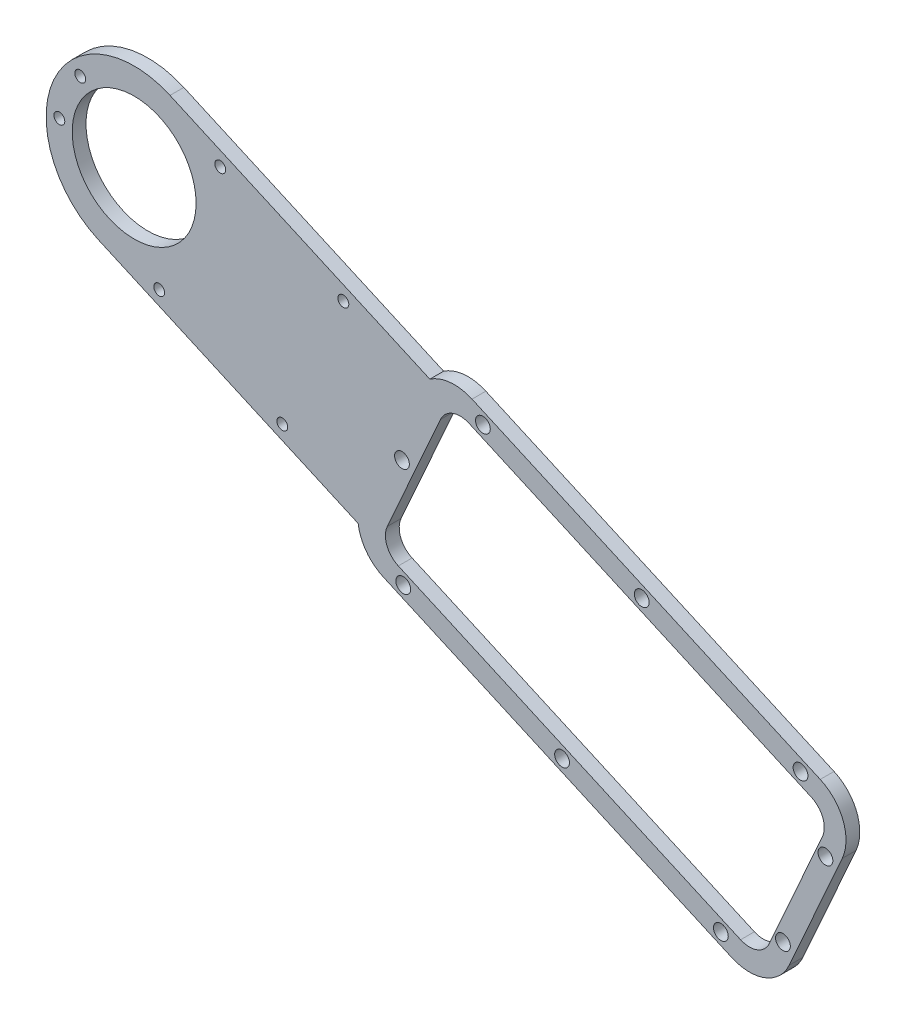
from build123d import *

# Parameters (mm, degrees)
SKETCH1_R           = 1.7
SKETCH1_R_2         = 14.25
SKETCH1_R_3         = 1.25
BOSS_EXTRUDE1_DEPTH = 3.175


with BuildPart() as part:
    # Sketch1 → Boss-Extrude1 (new body)
    with BuildSketch(Plane(origin=(0, 0, 0), x_dir=(-1, 0, 0), z_dir=(0, 0, -1))):
        with BuildLine():
            Line((67.653220557, 77.632201435), (79.867786674, 50.231391692))
            ThreePointArc((79.867786674, 50.231391692), (85.421957972, 44.965480094), (93.072911961, 45.169310483))
            Line((93.072911961, 45.169310483), (173.174612442, 80.876558766))
            ThreePointArc((173.174612442, 80.876558766), (177.109561802, 84.018800254), (179.014269534, 88.680301782))
            Line((179.014269534, 88.680301782), (238.78902448, 115.326328059))
            ThreePointArc((238.78902448, 115.326328059), (249.039738928, 142.066706765), (222.299360222, 152.317421212))
            Line((222.299360222, 152.317421212), (162.524605276, 125.671394934))
            ThreePointArc((162.524605276, 125.671394934), (157.784388135, 127.370762315), (152.817002247, 126.544575004))
            Line((152.817002247, 126.544575004), (72.715301765, 90.837326721))
            ThreePointArc((72.715301765, 90.837326721), (67.449390168, 85.283155423), (67.653220557, 77.632201435))
        make_face()
        with Locations((168.932649456, 106.357056211)):
            Circle(SKETCH1_R, mode=Mode.SUBTRACT)
        with Locations((71.52342211, 76.072861852)):
            Circle(SKETCH1_R, mode=Mode.SUBTRACT)
        with Locations((81.295075004, 54.152214057)):
            Circle(SKETCH1_R, mode=Mode.SUBTRACT)
        with Locations((77.249619525, 90.121461895)):
            Circle(SKETCH1_R, mode=Mode.SUBTRACT)
        with Locations((113.784032516, 106.407550051)):
            Circle(SKETCH1_R, mode=Mode.SUBTRACT)
        with Locations((150.318445506, 122.693638207)):
            Circle(SKETCH1_R, mode=Mode.SUBTRACT)
        with Locations((168.640294682, 81.592423593)):
            Circle(SKETCH1_R, mode=Mode.SUBTRACT)
        with Locations((132.105881692, 65.306335437)):
            Circle(SKETCH1_R, mode=Mode.SUBTRACT)
        with Locations((95.571468701, 49.02024728)):
            Circle(SKETCH1_R, mode=Mode.SUBTRACT)
        with Locations((230.544192351, 133.821874636)):
            Circle(SKETCH1_R_2, mode=Mode.SUBTRACT)
        with Locations((196.466353254, 99.744559857)):
            Circle(SKETCH1_R_3, mode=Mode.SUBTRACT)
        with Locations((224.780523322, 112.366278179)):
            Circle(SKETCH1_R_3, mode=Mode.SUBTRACT)
        with Locations((210.733772287, 143.877209383)):
            Circle(SKETCH1_R_3, mode=Mode.SUBTRACT)
        with Locations((182.419602219, 131.255491062)):
            Circle(SKETCH1_R_3, mode=Mode.SUBTRACT)
        with Locations((242.947351213, 145.810375386)):
            Circle(SKETCH1_R_3, mode=Mode.SUBTRACT)
        with Locations((247.751623016, 135.033002179)):
            Circle(SKETCH1_R_3, mode=Mode.SUBTRACT)
        with BuildLine():
            Line((74.751062785, 86.270525098), (153.492790079, 121.371532814))
            ThreePointArc((153.492790079, 121.371532814), (157.318267073, 121.473448009), (160.095352722, 118.84049221))
            Line((160.095352722, 118.84049221), (172.30991884, 91.439682467))
            ThreePointArc((172.30991884, 91.439682467), (172.411834034, 87.614205473), (169.778878235, 84.837119824))
            Line((169.778878235, 84.837119824), (91.037150941, 49.736112107))
            ThreePointArc((91.037150941, 49.736112107), (87.211673947, 49.634196913), (84.434588298, 52.267152711))
            Line((84.434588298, 52.267152711), (72.22002218, 79.667962454))
            ThreePointArc((72.22002218, 79.667962454), (72.118106986, 83.493439449), (74.751062785, 86.270525098))
        make_face(mode=Mode.SUBTRACT)
    extrude(amount=-BOSS_EXTRUDE1_DEPTH)


solid = part.part
